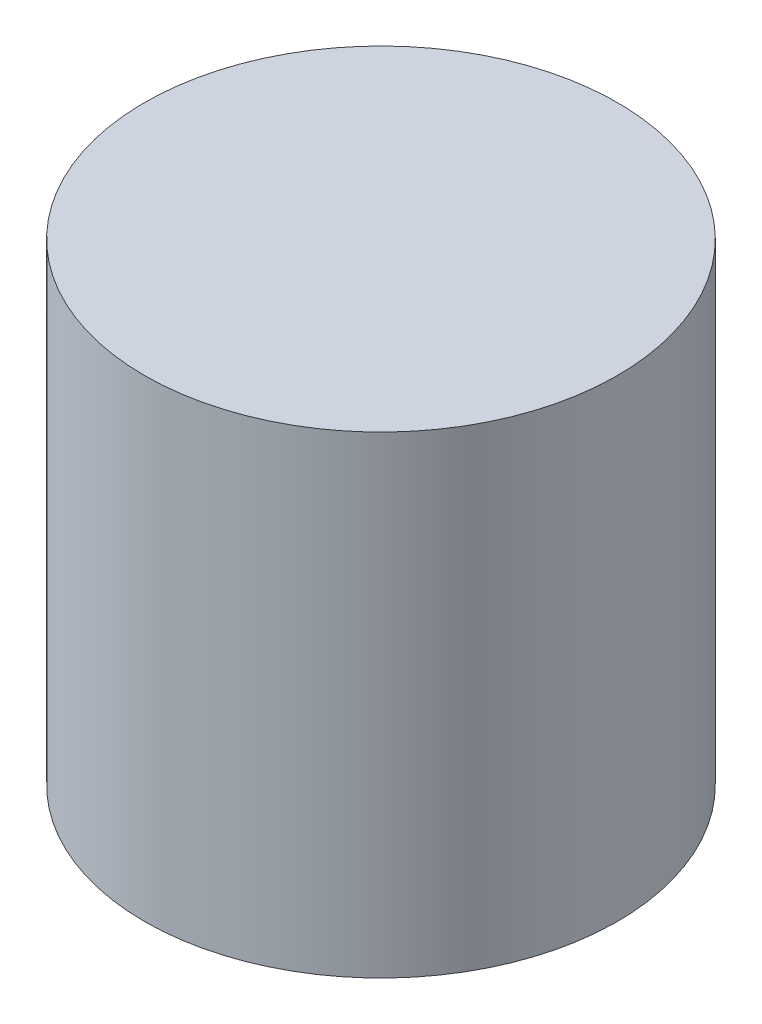
from build123d import *

# Parameters (mm, degrees)
SKETCH1_R           = 12.7
BOSS_EXTRUDE1_DEPTH = 25.4


with BuildPart() as part:
    # Sketch1 → Boss-Extrude1 (new body)
    with BuildSketch(Plane(origin=(0, 0, 0), x_dir=(1, 0, 0), z_dir=(0, 1, 0))):
        Circle(SKETCH1_R)
    extrude(amount=BOSS_EXTRUDE1_DEPTH)


solid = part.part
